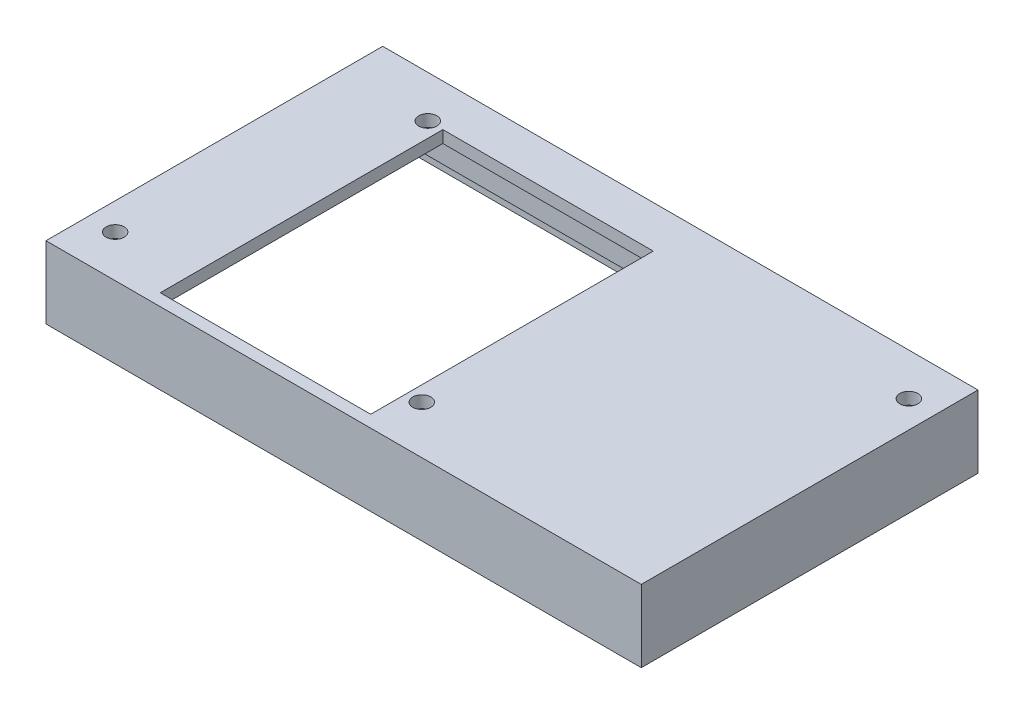
from build123d import *

# Parameters (mm, degrees)
SKETCH1_W                = 99
SKETCH1_H                = 56
SKETCH1_W_2              = 97
SKETCH1_H_2              = 54
SKETCH1_W_3              = 95
SKETCH1_H_3              = 52
BOSS_EXTRUDE1_DEPTH      = 2
SKETCH1_3_W              = 99
SKETCH1_3_H              = 56
SKETCH1_3_W_2            = 97
SKETCH1_3_H_2            = 54
BOSS_EXTRUDE2_DEPTH      = 10
SKETCH1_4_W              = 97
SKETCH1_4_H              = 54
SKETCH1_4_W_2            = 95
SKETCH1_4_H_2            = 52
BOSS_EXTRUDE3_DEPTH      = 8
F_3_0_3_DIAMETER_HOLE1_D = 3
CUT_EXTRUDE1_REACH       = 105.368
SKETCH7_W                = 20
SKETCH7_H                = 5
CUT_EXTRUDE2_REACH       = 77.407
SKETCH8_W                = 10
SKETCH8_H                = 5


with BuildPart() as part:
    # Sketch1 → Boss-Extrude1 (new body)
    with BuildSketch(Plane(origin=(0, 0, 0), x_dir=(1, 0, 0), z_dir=(0, 1, 0))):
        Rectangle(SKETCH1_W, SKETCH1_H)
        Rectangle(SKETCH1_W_2, SKETCH1_H_2, mode=Mode.SUBTRACT)
        Rectangle(SKETCH1_W_2, SKETCH1_H_2)
        Rectangle(SKETCH1_W_3, SKETCH1_H_3, mode=Mode.SUBTRACT)
        Polygon((47.5, 26), (-47.5, 26), (-47.5, -26), (-32.5, -26), (-32.5, 21), (2.5, 21), (2.5, -26), (47.5, -26), align=None)
    extrude(amount=BOSS_EXTRUDE1_DEPTH)

    # Sketch1_3 → Boss-Extrude2 (add)
    with BuildSketch(Plane(origin=(0, 0, 0), x_dir=(1, 0, 0), z_dir=(0, 1, 0))):
        Rectangle(SKETCH1_3_W, SKETCH1_3_H)
        Rectangle(SKETCH1_3_W_2, SKETCH1_3_H_2, mode=Mode.SUBTRACT)
    extrude(amount=-BOSS_EXTRUDE2_DEPTH)

    # Sketch1_4 → Boss-Extrude3 (add)
    with BuildSketch(Plane(origin=(0, 0, 0), x_dir=(1, 0, 0), z_dir=(0, 1, 0))):
        Rectangle(SKETCH1_4_W, SKETCH1_4_H)
        Rectangle(SKETCH1_4_W_2, SKETCH1_4_H_2, mode=Mode.SUBTRACT)
    extrude(amount=-BOSS_EXTRUDE3_DEPTH)

    # Ø3.0 (3) Diameter Hole1 (through all)
    with Locations(Plane(origin=(0, 0, 0), x_dir=(-1, 0, 0), z_dir=(0, -1, 0))):
        with Locations((-45, 21), (45, -21), (35, 21), (-5, -20)):
            Hole(F_3_0_3_DIAMETER_HOLE1_D / 2)

    # Cut-Extrude1: up to this face of the body (flat: up to its plane)
    cut_extrude1_end = Plane(part.part.faces().sort_by_distance((-47.5, -4, 0))[0])
    # Sketch7 → Cut-Extrude1 (cut, up to the picked face)
    with BuildSketch(Plane.ZY.offset(49.5), mode=Mode.PRIVATE) as cut_extrude1_sk1:
        with Locations((-2, -7.5)):
            Rectangle(SKETCH7_W, SKETCH7_H)
    cut_extrude1_tool1 = split(extrude(cut_extrude1_sk1.sketch, amount=-CUT_EXTRUDE1_REACH, mode=Mode.PRIVATE), bisect_by=cut_extrude1_end, keep=Keep.BOTH, mode=Mode.PRIVATE)
    add(cut_extrude1_tool1.solids().sort_by(Axis((-49.5, -7.5, -2), (1, 0, 0)))[0], mode=Mode.SUBTRACT)

    # Sketch8 → Cut-Extrude2 (cut, up to next)
    with BuildSketch(Plane(origin=(0, 0, -28), x_dir=(-1, 0, 0), z_dir=(0, 0, -1)), mode=Mode.PRIVATE) as cut_extrude2_sk1:
        with Locations((-24.5, -7.5)):
            Rectangle(SKETCH8_W, SKETCH8_H)
    cut_extrude2_tool1 = extrude(cut_extrude2_sk1.sketch, amount=-CUT_EXTRUDE2_REACH, mode=Mode.PRIVATE) & part.part
    add(cut_extrude2_tool1.solids().sort_by_distance((24.5, -7.5, -28))[0], mode=Mode.SUBTRACT)


solid = part.part
